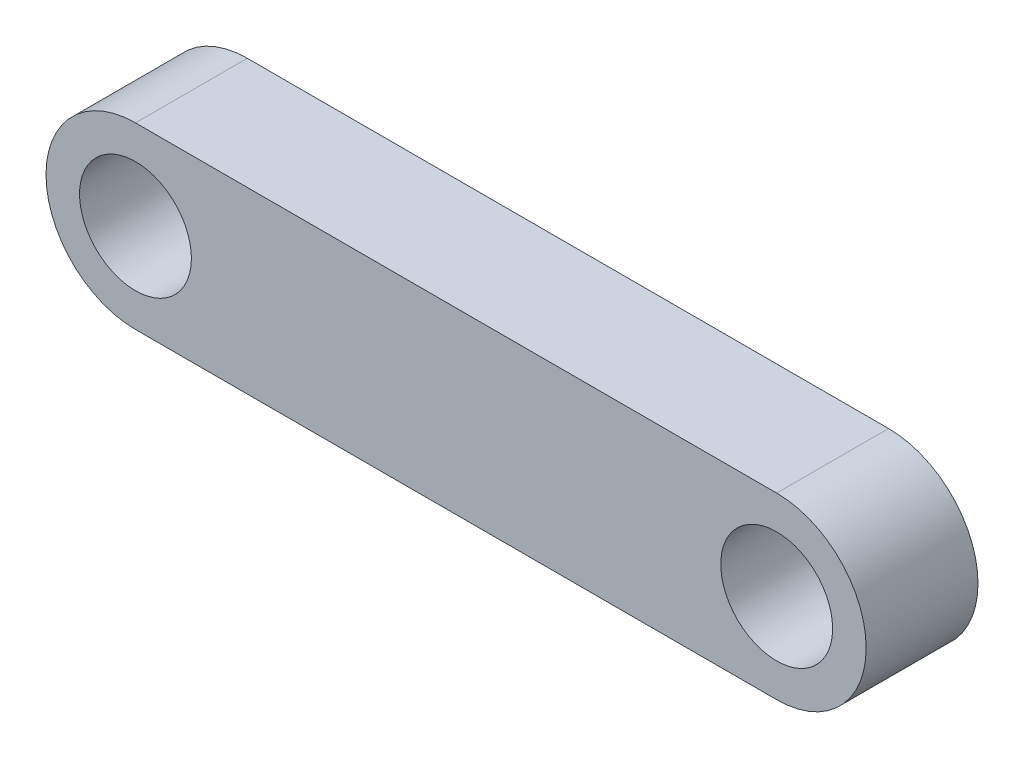
from build123d import *

# Parameters (mm, degrees)
ESQUISSE4_R        = 1.5
BOSS_EXTRU_4_DEPTH = 3


with BuildPart() as part:
    # Esquisse4 → Boss.-Extru.4 (new body)
    with BuildSketch(Plane.XY):
        with BuildLine():
            Line((-19.332562651, 36.187093075), (-2.132901247, 36.187093075))
            ThreePointArc((-2.132901247, 36.187093075), (0.267098753, 33.787093075), (-2.132901247, 31.387093075))
            Line((-2.132901247, 31.387093075), (-19.332562651, 31.387093075))
            ThreePointArc((-19.332562651, 31.387093075), (-21.732562651, 33.787093075), (-19.332562651, 36.187093075))
        make_face()
        with Locations((-19.332562651, 33.787093075)):
            Circle(ESQUISSE4_R, mode=Mode.SUBTRACT)
        with Locations((-2.132901247, 33.787093075)):
            Circle(ESQUISSE4_R, mode=Mode.SUBTRACT)
    extrude(amount=BOSS_EXTRU_4_DEPTH)


solid = part.part
